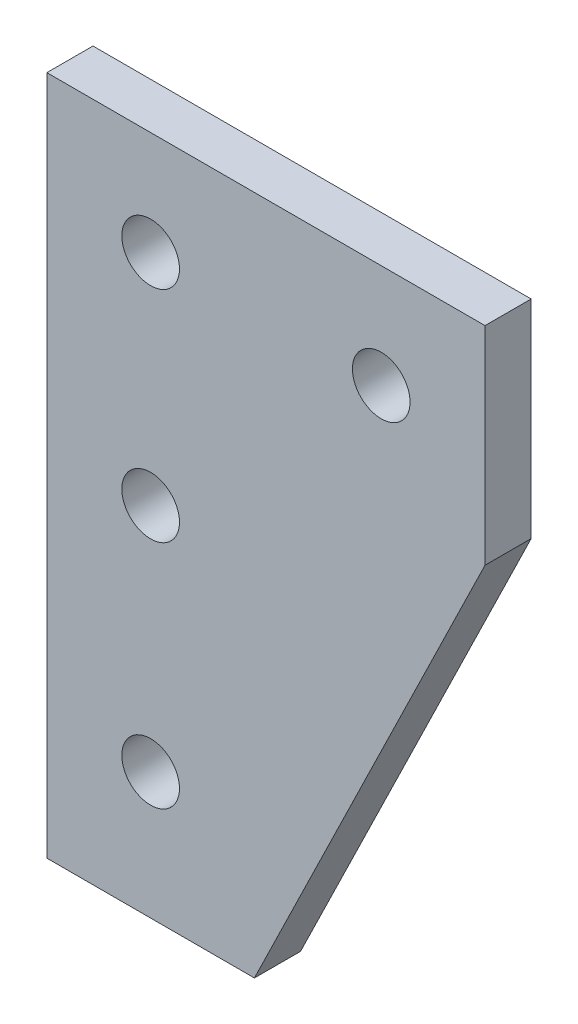
from build123d import *

# Parameters (mm, degrees)
SKETCH_1_W          = 50
SKETCH_1_H          = 50
EXTRUDE_1_DEPTH     = 2
SKETCH_3_W          = 76.549088161
SKETCH_3_H          = 63.496312915
CUT_EXTRUDE_3_DEPTH = 10
M3X0_5_1_D          = 2.5
M3X0_5_1_DEPTH      = 8.5
M3X0_5_1_TIP        = 0.751075774


with BuildPart() as part:
    # ｽｹｯﾁ1 → ﾎﾞｽ - 押し出し1 (new body)
    with BuildSketch(Plane.XY):
        Rectangle(SKETCH_1_W, SKETCH_1_H)
    extrude(amount=EXTRUDE_1_DEPTH)

    # ｽｹｯﾁ3 → ｶｯﾄ - 押し出し3 (cut)
    with BuildSketch(Plane.XY.offset(2)):
        with Locations((-0.951764861, 3.501134841)):
            Rectangle(SKETCH_3_W, SKETCH_3_H)
        Polygon((14.5, -4.5), (4.5, -25), (-4.5, -25), (-4.5, 4.5), (14.5, 4.5), align=None, mode=Mode.SUBTRACT)
    extrude(amount=-CUT_EXTRUDE_3_DEPTH, mode=Mode.SUBTRACT)

    # M3x0.5 ねじ穴1
    with Locations(Plane.XY.offset(2)):
        with Locations((0, 0), (10, 0), (0, -9.51), (0, -19.51)):
            Hole(M3X0_5_1_D / 2, depth=M3X0_5_1_DEPTH)
            with Locations((0, 0, -(M3X0_5_1_DEPTH + M3X0_5_1_TIP / 2))):  # 118° drill point
                Cone(0, M3X0_5_1_D / 2, M3X0_5_1_TIP, mode=Mode.SUBTRACT)


solid = part.part
